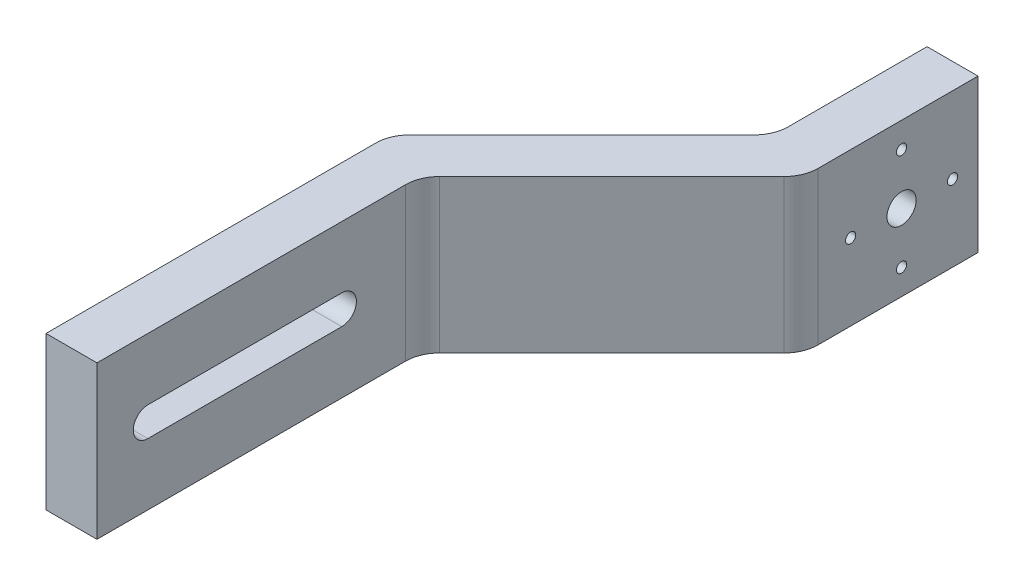
from build123d import *

# Parameters (mm, degrees)
BODY_DEPTH                            = 45
MOUNTING_HOLES_REACH                  = 17
SKETCH3_R                             = 4.3
SKETCH3_R_2                           = 1.5
MOUNTING_HOLE_COUNTERBORE_DEPTH       = 3.5
STRESS_CONCENTRATION_RELIEF_FILLETS_R = 10
SLOT_DEPTH                            = 72.568542495


with BuildPart() as part:
    # Sketch1 → Body (new body)
    with BuildSketch(Plane(origin=(0, 0, 0), x_dir=(1, 0, 0), z_dir=(0, 1, 0))):
        Polygon((0, 0), (0, 101.213203436), (56.568542495, 157.781745931), (56.568542495, 202.781745931), (71.568542495, 202.781745931), (71.568542495, 151.568542495), (15, 95), (15, 0), align=None)
    extrude(amount=BODY_DEPTH)

    # Sketch3 → Mounting Holes (cut, up to next)
    with BuildSketch(Plane.ZY.offset(-56.568542495), mode=Mode.PRIVATE) as mounting_holes_sk1:
        with Locations((-180.281745931, 22.5)):
            Circle(SKETCH3_R)
    mounting_holes_tool1 = extrude(mounting_holes_sk1.sketch, amount=-MOUNTING_HOLES_REACH, mode=Mode.PRIVATE) & part.part
    add(mounting_holes_tool1.solids().sort_by_distance((56.568542, 22.5, -180.281746))[0], mode=Mode.SUBTRACT)
    # Sketch3 → Mounting Holes (cut, up to next)
    with BuildSketch(Plane.ZY.offset(-56.568542495), mode=Mode.PRIVATE) as mounting_holes_sk2:
        with Locations((-180.281745931, 37.5)):
            Circle(SKETCH3_R_2)
    mounting_holes_tool2 = extrude(mounting_holes_sk2.sketch, amount=-MOUNTING_HOLES_REACH, mode=Mode.PRIVATE) & part.part
    add(mounting_holes_tool2.solids().sort_by_distance((56.568542, 37.5, -180.281746))[0], mode=Mode.SUBTRACT)
    # Sketch3 → Mounting Holes (cut, up to next)
    with BuildSketch(Plane.ZY.offset(-56.568542495), mode=Mode.PRIVATE) as mounting_holes_sk3:
        with Locations((-165.281745931, 22.5)):
            Circle(SKETCH3_R_2)
    mounting_holes_tool3 = extrude(mounting_holes_sk3.sketch, amount=-MOUNTING_HOLES_REACH, mode=Mode.PRIVATE) & part.part
    add(mounting_holes_tool3.solids().sort_by_distance((56.568542, 22.5, -165.281746))[0], mode=Mode.SUBTRACT)
    # Sketch3 → Mounting Holes (cut, up to next)
    with BuildSketch(Plane.ZY.offset(-56.568542495), mode=Mode.PRIVATE) as mounting_holes_sk4:
        with Locations((-180.281745931, 7.5)):
            Circle(SKETCH3_R_2)
    mounting_holes_tool4 = extrude(mounting_holes_sk4.sketch, amount=-MOUNTING_HOLES_REACH, mode=Mode.PRIVATE) & part.part
    add(mounting_holes_tool4.solids().sort_by_distance((56.568542, 7.5, -180.281746))[0], mode=Mode.SUBTRACT)
    # Sketch3 → Mounting Holes (cut, up to next)
    with BuildSketch(Plane.ZY.offset(-56.568542495), mode=Mode.PRIVATE) as mounting_holes_sk5:
        with Locations((-195.281745931, 22.5)):
            Circle(SKETCH3_R_2)
    mounting_holes_tool5 = extrude(mounting_holes_sk5.sketch, amount=-MOUNTING_HOLES_REACH, mode=Mode.PRIVATE) & part.part
    add(mounting_holes_tool5.solids().sort_by_distance((56.568542, 22.5, -195.281746))[0], mode=Mode.SUBTRACT)

    # Sketch4 → Mounting Hole Counterbore (cut)
    with BuildSketch(Plane.ZY.offset(-56.568542495)):
        Polygon((-162.431745931, 20.854551733), (-162.431745931, 24.145448267), (-165.281745931, 25.790896534), (-168.131745931, 24.145448267), (-168.131745931, 20.854551733), (-165.281745931, 19.209103466), align=None)
        Polygon((-178.636297663, 40.35), (-181.927194198, 40.35), (-183.572642465, 37.5), (-181.927194198, 34.65), (-178.636297663, 34.65), (-176.990849396, 37.5), align=None)
        Polygon((-181.927194198, 4.65), (-178.636297663, 4.65), (-176.990849396, 7.5), (-178.636297663, 10.35), (-181.927194198, 10.35), (-183.572642465, 7.5), align=None)
        Polygon((-198.131745931, 24.145448267), (-198.131745931, 20.854551733), (-195.281745931, 19.209103466), (-192.431745931, 20.854551733), (-192.431745931, 24.145448267), (-195.281745931, 25.790896534), align=None)
    extrude(amount=-MOUNTING_HOLE_COUNTERBORE_DEPTH, mode=Mode.SUBTRACT)

    # Stress Concentration Relief Fillets
    stress_concentration_relief_fillets_edges = [part.edges().sort_by_distance(p)[0] for p in [
        (0, 22.5, -101.213203436),
        (56.568542495, 22.5, -157.781745931),
        (71.568542495, 22.5, -151.568542495),
        (15, 22.5, -95),
    ]]
    fillet(stress_concentration_relief_fillets_edges, radius=STRESS_CONCENTRATION_RELIEF_FILLETS_R)

    # Sketch5 → Slot (cut, through all)
    with BuildSketch(Plane.ZY):
        with BuildLine():
            Line((-72.071067812, 26.8), (-15, 26.8))
            ThreePointArc((-15, 26.8), (-10.7, 22.5), (-15, 18.2))
            Line((-15, 18.2), (-72.071067812, 18.2))
            ThreePointArc((-72.071067812, 18.2), (-76.371067812, 22.5), (-72.071067812, 26.8))
        make_face()
    extrude(amount=-SLOT_DEPTH, mode=Mode.SUBTRACT)


solid = part.part
